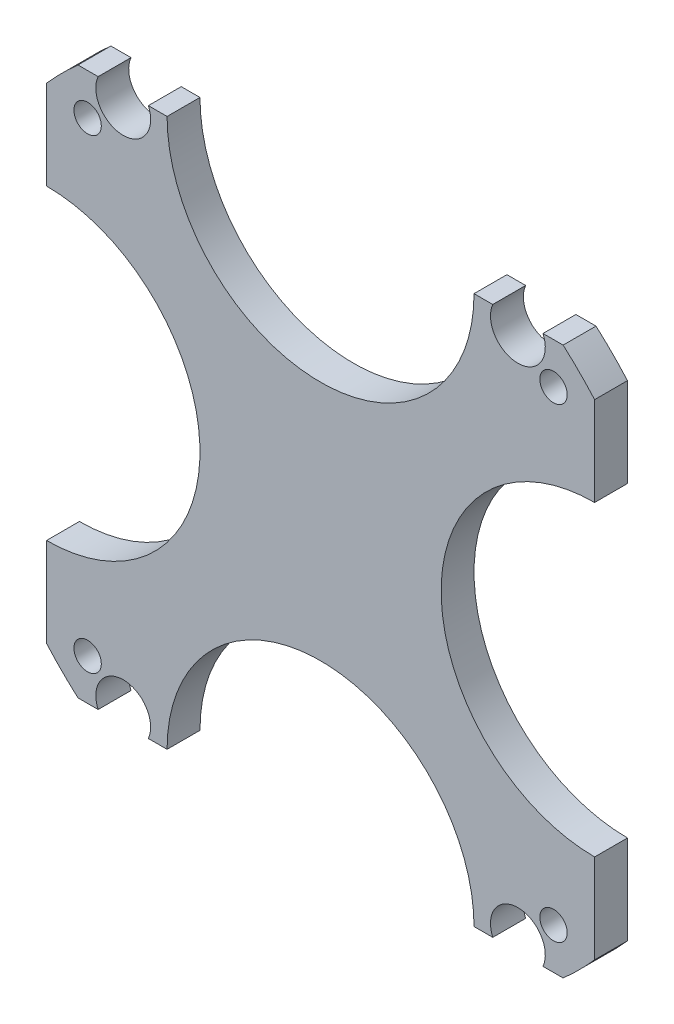
from build123d import *

# Parameters (mm, degrees)
SKETCH_1_R          = 1.25
EXTRUDE_1_DEPTH     = 3
SKETCH_2_R          = 2.5
CUT_EXTRUDE_1_DEPTH = 12


with BuildPart() as part:
    # 草图1 → 凸台-拉伸1 (new body)
    with BuildSketch(Plane.XY):
        with BuildLine():
            Line((-14, 25), (-22.127465978, 25))
            ThreePointArc((-22.127465978, 25), (-23.607464398, 23.607464398), (-25, 22.127465978))
            Line((-25, 22.127465978), (-25, 14))
            ThreePointArc((-25, 14), (-15.100505063, 9.899494937), (-11, 0))
            ThreePointArc((-11, 0), (-15.100505063, -9.899494937), (-25, -14))
            Line((-25, -14), (-25, -22.127465978))
            ThreePointArc((-25, -22.127465978), (-23.607464398, -23.607464398), (-22.127465978, -25))
            Line((-22.127465978, -25), (-14, -25))
            ThreePointArc((-14, -25), (0, -11), (14, -25))
            Line((14, -25), (22.127465978, -25))
            ThreePointArc((22.127465978, -25), (23.607464398, -23.607464398), (25, -22.127465978))
            Line((25, -22.127465978), (25, -14))
            ThreePointArc((25, -14), (11, 0), (25, 14))
            Line((25, 14), (25, 22.127465978))
            ThreePointArc((25, 22.127465978), (23.607464398, 23.607464398), (22.127465978, 25))
            Line((22.127465978, 25), (14, 25))
            ThreePointArc((14, 25), (0, 11), (-14, 25))
        make_face()
        with Locations((-21.25, -21.25)):
            Circle(SKETCH_1_R, mode=Mode.SUBTRACT)
        with Locations((21.25, -21.25)):
            Circle(SKETCH_1_R, mode=Mode.SUBTRACT)
        with Locations((-21.25, 21.25)):
            Circle(SKETCH_1_R, mode=Mode.SUBTRACT)
        with Locations((21.25, 21.25)):
            Circle(SKETCH_1_R, mode=Mode.SUBTRACT)
    extrude(amount=EXTRUDE_1_DEPTH)

    # 草图2 → 切除-拉伸1 (cut)
    with BuildSketch(Plane.XY.offset(3)):
        with BuildLine():
            ThreePointArc((20.291287847, 25), (18, 26.5), (15.708712153, 25))
            Line((15.708712153, 25), (20.291287847, 25))
        make_face()
        with BuildLine():
            Line((20.291287847, 25), (15.708712153, 25))
            ThreePointArc((15.708712153, 25), (17.489225891, 21.552734218), (20.5, 24))
            ThreePointArc((20.5, 24), (20.447265782, 24.510774109), (20.291287847, 25))
        make_face()
        with BuildLine():
            ThreePointArc((20.5, -24), (17.489225891, -21.552734218), (15.708712153, -25))
            Line((15.708712153, -25), (20.291287847, -25))
            ThreePointArc((20.291287847, -25), (20.447265782, -24.510774109), (20.5, -24))
        make_face()
        with BuildLine():
            Line((20.291287847, -25), (15.708712153, -25))
            ThreePointArc((15.708712153, -25), (18, -26.5), (20.291287847, -25))
        make_face()
        with Locations((-18, 24)):
            Circle(SKETCH_2_R)
        with Locations((-18, -24)):
            Circle(SKETCH_2_R)
    extrude(amount=-CUT_EXTRUDE_1_DEPTH, mode=Mode.SUBTRACT)


solid = part.part
